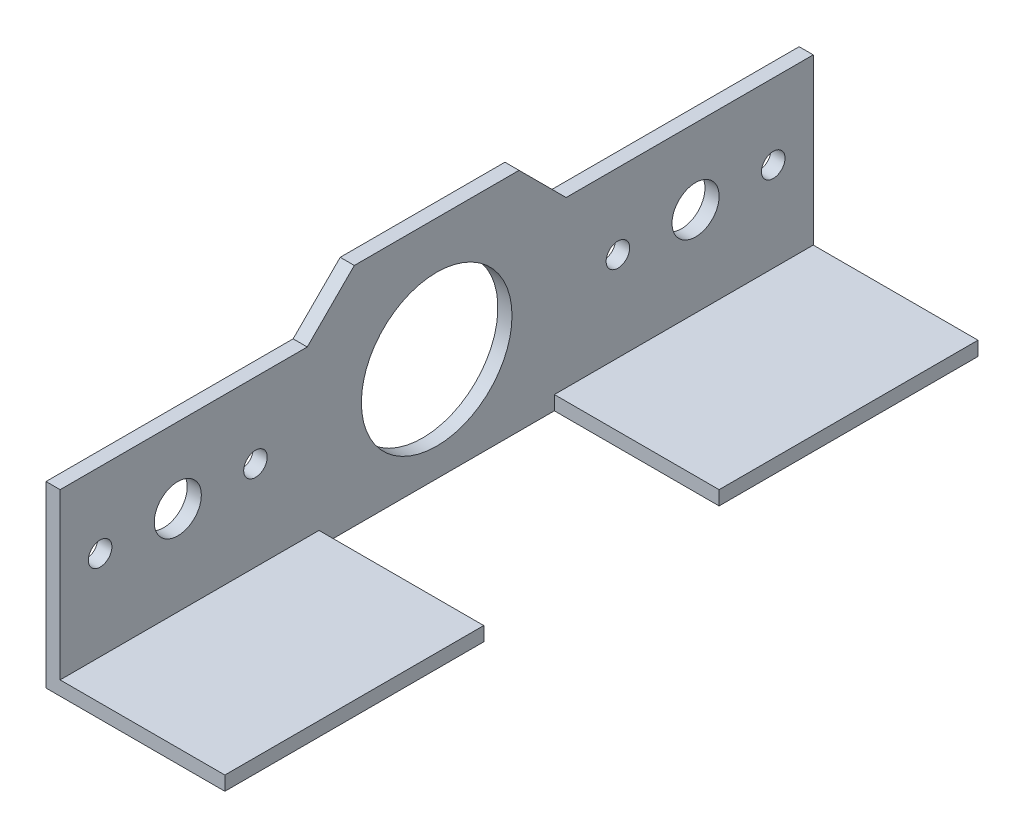
from build123d import *

# Parameters (mm, degrees)
SALIENTE_EXTRUIR1_DEPTH      = 80
SALIENTE_EXTRUIR1_DEPTH_BACK = 80
CROQUIS2_W                   = 35
CROQUIS2_H                   = 50
CORTAR_EXTRUIR1_DEPTH        = 3
CROQUIS3_R                   = 2.5
CROQUIS3_R_2                 = 5
CORTAR_EXTRUIR2_DEPTH        = 3
SALIENTE_EXTRUIR2_DEPTH      = 3
CROQUIS5_R                   = 16
CORTAR_EXTRUIR3_DEPTH        = 3


with BuildPart() as part:
    # Croquis1 → Saliente-Extruir1 (new body, two sides)
    with BuildSketch(Plane.XY) as saliente_extruir1_sk:
        Polygon((0, 0), (0, 38), (3, 38), (3, 3), (38, 3), (38, 0), align=None)
    extrude(amount=SALIENTE_EXTRUIR1_DEPTH)
    extrude(saliente_extruir1_sk.sketch, amount=-SALIENTE_EXTRUIR1_DEPTH_BACK)

    # Croquis2 → Cortar-Extruir1 (cut)
    with BuildSketch(Plane(origin=(0, 3, 0), x_dir=(1, 0, 0), z_dir=(0, 1, 0))):
        with Locations((20.5, 0)):
            Rectangle(CROQUIS2_W, CROQUIS2_H)
    extrude(amount=-CORTAR_EXTRUIR1_DEPTH, mode=Mode.SUBTRACT)

    # Croquis3 → Cortar-Extruir2 (cut)
    with BuildSketch(Plane.ZY):
        with Locations((71.5, 22)):
            Circle(CROQUIS3_R)
        with Locations((55, 22)):
            Circle(CROQUIS3_R_2)
        with Locations((38.5, 22)):
            Circle(CROQUIS3_R)
        with Locations((-38.5, 22)):
            Circle(CROQUIS3_R)
        with Locations((-55, 22)):
            Circle(CROQUIS3_R_2)
        with Locations((-71.5, 22)):
            Circle(CROQUIS3_R)
    extrude(amount=-CORTAR_EXTRUIR2_DEPTH, mode=Mode.SUBTRACT)

    # Croquis4 → Saliente-Extruir2 (add)
    with BuildSketch(Plane.ZY):
        Polygon((27.5, 38), (17.5, 48), (-17.5, 48), (-27.5, 38), align=None)
    extrude(amount=-SALIENTE_EXTRUIR2_DEPTH)

    # Croquis5 → Cortar-Extruir3 (cut)
    with BuildSketch(Plane.ZY):
        with Locations((0, 22)):
            Circle(CROQUIS5_R)
    extrude(amount=-CORTAR_EXTRUIR3_DEPTH, mode=Mode.SUBTRACT)


solid = part.part
